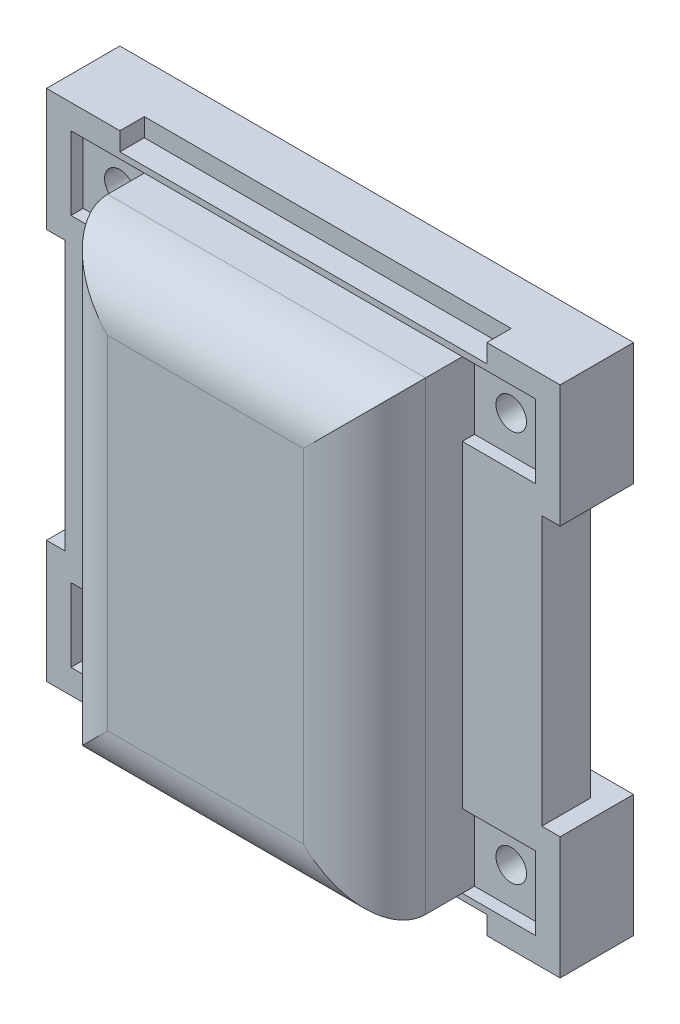
from build123d import *

# Parameters (mm, degrees)
SKETCH_1_W               = 26
SKETCH_1_H               = 38
EXTRUDE_1_DEPTH          = 12
SKETCH_2_W               = 22
SKETCH_2_H               = 34
CUT_EXTRUDE_1_DEPTH      = 10
SKETCH_4_W               = 6
SKETCH_4_H               = 6
EXTRUDE_2_DEPTH          = 3
FILLET_1_R               = 5
SKETCH_6_W               = 30
SKETCH_6_H               = 42
SKETCH_6_W_2             = 27
SKETCH_6_H_2             = 39
EXTRUDE_3_DEPTH          = 2
EXTRUDE_3_DEPTH_BACK     = 2
SKETCH_5_R               = 1.25
CUT_EXTRUDE_4_DEPTH      = 13
CUT_EXTRUDE_4_DEPTH_BACK = 3
CUT_EXTRUDE_START        = 5
SKETCH_7_W               = 7
SKETCH_7_H               = 7
CUT_EXTRUDE_5_DEPTH      = 2
EXTRUDE_4_DEPTH          = 4
EXTRUDE_4_DEPTH_BACK     = 2
SKETCH_9_W               = 21
SKETCH_9_H               = 33
SKETCH_9_W_2             = 18
SKETCH_9_H_2             = 30
EXTRUDE_5_DEPTH          = 2
EXTRUDE_5_DEPTH_BACK     = 8
SKETCH_11_W              = 39
SKETCH_11_H              = 39
EXTRUDE_9_DEPTH          = 2
EXTRUDE_9_DEPTH_BACK     = 2


with BuildPart() as part:
    # ｽｹｯﾁ1 → ﾎﾞｽ - 押し出し1 (new body)
    with BuildSketch(Plane.XY):
        Rectangle(SKETCH_1_W, SKETCH_1_H)
    extrude(amount=EXTRUDE_1_DEPTH)

    # ｽｹｯﾁ2 → ｶｯﾄ - 押し出し1 (cut)
    with BuildSketch(Plane.XY):
        Rectangle(SKETCH_2_W, SKETCH_2_H)
    extrude(amount=CUT_EXTRUDE_1_DEPTH, mode=Mode.SUBTRACT)

    # ｽｹｯﾁ4 → ﾎﾞｽ - 押し出し2 (add)
    with BuildSketch(Plane.XY):
        with Locations((16, 16)):
            Rectangle(SKETCH_4_W, SKETCH_4_H)
        with Locations((16, -16)):
            Rectangle(SKETCH_4_W, SKETCH_4_H)
        with Locations((-16, -16)):
            Rectangle(SKETCH_4_W, SKETCH_4_H)
        with Locations((-16, 16)):
            Rectangle(SKETCH_4_W, SKETCH_4_H)
    extrude(amount=EXTRUDE_2_DEPTH)

    # ﾌｨﾚｯﾄ1
    fillet_1_edges = [part.edges().sort_by_distance(p)[0] for p in [
        (0, 19, 12),
        (0, -19, 12),
        (13, 0, 12),
        (-13, 0, 12),
    ]]
    fillet(fillet_1_edges, radius=FILLET_1_R)

    # ｽｹｯﾁ6 → ﾎﾞｽ - 押し出し3 (add, two sides)
    with BuildSketch(Plane(origin=(0, 0, 0), x_dir=(-1, 0, 0), z_dir=(0, 0, -1))) as extrude_3_sk:
        Rectangle(SKETCH_6_W, SKETCH_6_H)
        Rectangle(SKETCH_6_W_2, SKETCH_6_H_2, mode=Mode.SUBTRACT)
    extrude(amount=EXTRUDE_3_DEPTH)
    extrude(extrude_3_sk.sketch, amount=-EXTRUDE_3_DEPTH_BACK)

    # ｽｹｯﾁ5 → ｶｯﾄ - 押し出し4 (cut, two sides)
    with BuildSketch(Plane.XY) as cut_extrude_4_sk:
        with Locations((-16, 16)):
            Circle(SKETCH_5_R)
        with Locations((-16, -16)):
            Circle(SKETCH_5_R)
        with Locations((16, -16)):
            Circle(SKETCH_5_R)
        with Locations((16, 16)):
            Circle(SKETCH_5_R)
    extrude(amount=CUT_EXTRUDE_4_DEPTH, mode=Mode.SUBTRACT)
    extrude(cut_extrude_4_sk.sketch, amount=-CUT_EXTRUDE_4_DEPTH_BACK, mode=Mode.SUBTRACT)

    # ｽｹｯﾁ7 → ｶｯﾄ - 押し出し5 (cut)
    with BuildSketch(Plane(origin=(0, 0, 3), x_dir=(-1, 0, 0), z_dir=(0, 0, -1)).offset(CUT_EXTRUDE_START)):
        with Locations((-16, 16)):
            Rectangle(SKETCH_7_W, SKETCH_7_H)
        with Locations((16, 16)):
            Rectangle(SKETCH_7_W, SKETCH_7_H)
        with Locations((16, -16)):
            Rectangle(SKETCH_7_W, SKETCH_7_H)
        with Locations((-16, -16)):
            Rectangle(SKETCH_7_W, SKETCH_7_H)
    extrude(amount=-CUT_EXTRUDE_5_DEPTH, mode=Mode.SUBTRACT)

    # ｽｹｯﾁ8 → ﾎﾞｽ - 押し出し4 (add, two sides)
    with BuildSketch(Plane.XY) as extrude_4_sk:
        Polygon((15, 21), (15, 19.5), (19.5, 19.5), (19.5, 12.5), (15, 12.5), (15, 11), (21, 11), (21, 21), align=None)
        Polygon((-15, 21), (-15, 19.5), (-19.5, 19.5), (-19.5, 12.5), (-15, 12.5), (-15, 11), (-21, 11), (-21, 21), align=None)
        Polygon((15, -21), (21, -21), (21, -11), (15, -11), (15, -12.5), (19.5, -12.5), (19.5, -19.5), (15, -19.5), align=None)
        Polygon((-21, -21), (-15, -21), (-15, -19.5), (-19.5, -19.5), (-19.5, -12.5), (-15, -12.5), (-15, -11), (-21, -11), align=None)
    extrude(amount=EXTRUDE_4_DEPTH)
    extrude(extrude_4_sk.sketch, amount=-EXTRUDE_4_DEPTH_BACK)

    # ｽｹｯﾁ11 → ﾎﾞｽ - 押し出し9 (add, two sides)
    with BuildSketch(Plane.XY.offset(2)) as extrude_9_sk:
        Rectangle(SKETCH_11_W, SKETCH_11_H)
        Polygon((-19, 13), (-13, 13), (-13, -13), (-19, -13), (-19, -19), (19, -19), (19, -13), (13, -13), (13, 13), (19, 13), (19, 19), (-19, 19), align=None, mode=Mode.SUBTRACT)
    extrude(amount=EXTRUDE_9_DEPTH)
    extrude(extrude_9_sk.sketch, amount=-EXTRUDE_9_DEPTH_BACK)


with BuildPart() as body_2:
    # ｽｹｯﾁ9 → ﾎﾞｽ - 押し出し5 (new body, two sides)
    with BuildSketch(Plane(origin=(0, 0, 0), x_dir=(-1, 0, 0), z_dir=(0, 0, -1))) as extrude_5_sk:
        Rectangle(SKETCH_9_W, SKETCH_9_H)
        Rectangle(SKETCH_9_W_2, SKETCH_9_H_2, mode=Mode.SUBTRACT)
    extrude(amount=EXTRUDE_5_DEPTH)
    extrude(extrude_5_sk.sketch, amount=-EXTRUDE_5_DEPTH_BACK)


solid = Compound([part.part, body_2.part])
